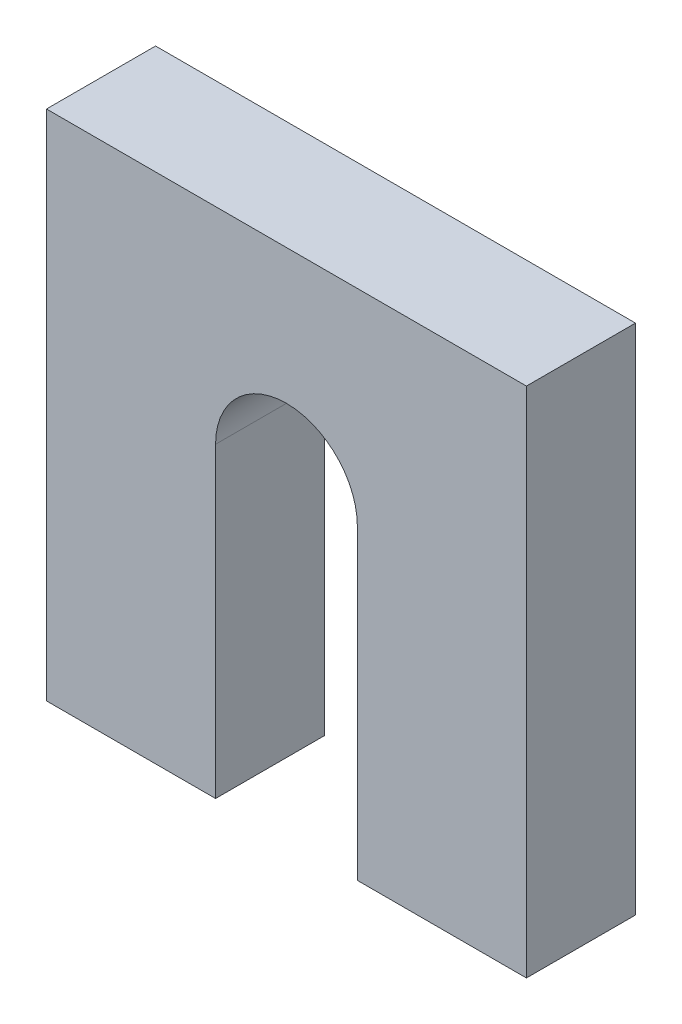
from build123d import *

# Parameters (mm, degrees)
SKETCH2_W           = 44
SKETCH2_H           = 47
BOSS_EXTRUDE1_DEPTH = 10
CUT_EXTRUDE1_DEPTH  = 10


with BuildPart() as part:
    # Sketch2 → Boss-Extrude1 (new body)
    with BuildSketch(Plane.XY):
        Rectangle(SKETCH2_W, SKETCH2_H)
    extrude(amount=BOSS_EXTRUDE1_DEPTH)

    # Sketch3 → Cut-Extrude1 (cut)
    with BuildSketch(Plane.XY.offset(10)):
        with BuildLine():
            Line((-6.5, -23.5), (-6.5, 4.628280517))
            ThreePointArc((-6.5, 4.628280517), (0, 11.128280517), (6.5, 4.628280517))
            Line((6.5, 4.628280517), (6.5, -23.5))
            ThreePointArc((6.5, -23.5), (0, -30), (-6.5, -23.5))
        make_face()
    extrude(amount=-CUT_EXTRUDE1_DEPTH, mode=Mode.SUBTRACT)


solid = part.part
